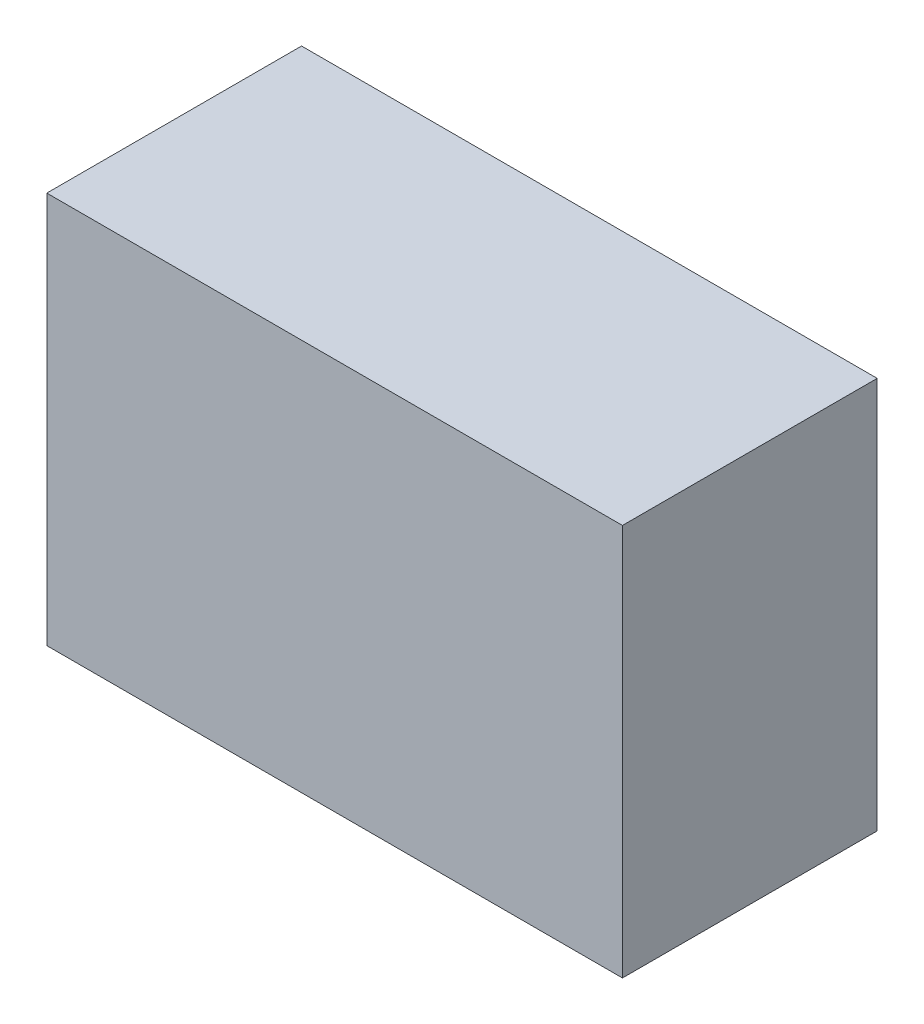
from build123d import *

# Parameters (mm, degrees)
SKETCH2_W      = 149.225
SKETCH2_H      = 66.04
EXTRUDE1_DEPTH = 101.6


with BuildPart() as part:
    # Sketch2 → Extrude1 (new body)
    with BuildSketch(Plane(origin=(0, 0, 0), x_dir=(1, 0, 0), z_dir=(0, 1, 0))):
        Rectangle(SKETCH2_W, SKETCH2_H)
    extrude(amount=EXTRUDE1_DEPTH)


solid = part.part
